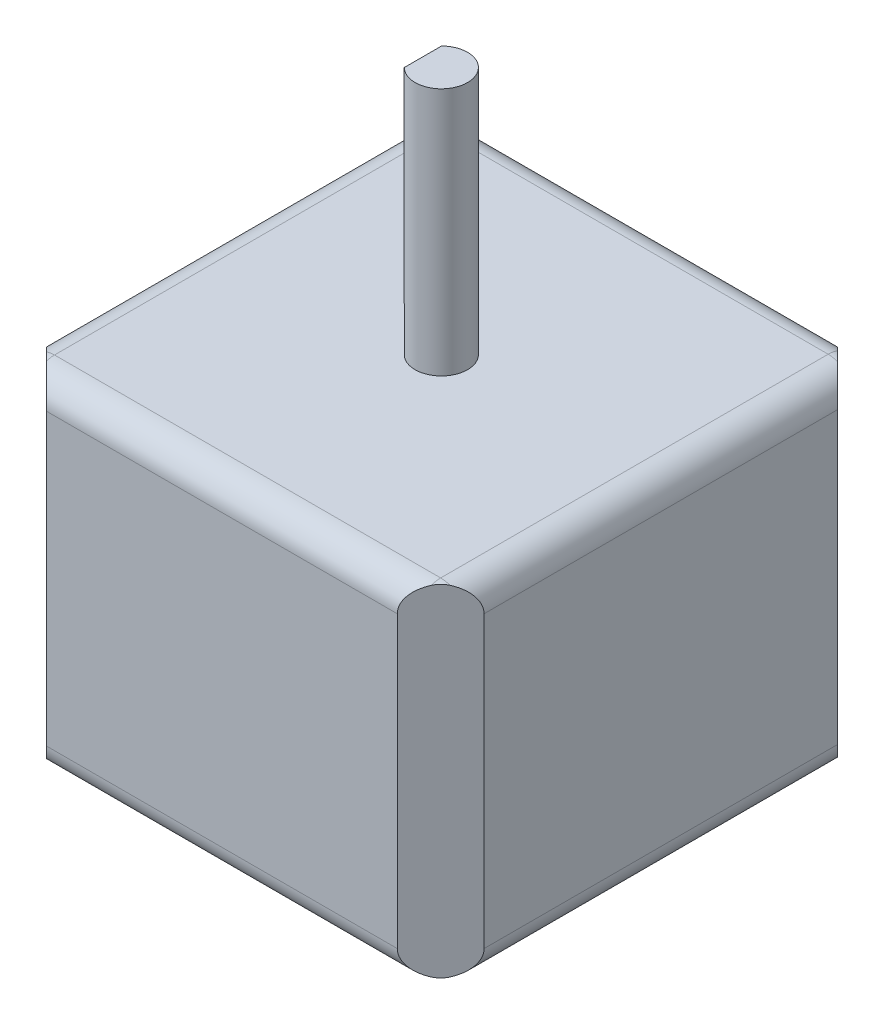
from build123d import *

# Parameters (mm, degrees)
SKETCH1_W           = 42.291
SKETCH1_H           = 33.02
BOSS_EXTRUDE1_DEPTH = 42.418
FILLET1_R           = 2.54
SKETCH2_R           = 2.5273
BOSS_EXTRUDE2_DEPTH = 23.9649
CUT_EXTRUDE2_DEPTH  = 18.288
CUT_EXTRUDE3_REACH  = 58.985


with BuildPart() as part:
    # Sketch1 → Boss-Extrude1 (new body)
    with BuildSketch(Plane.XY):
        Rectangle(SKETCH1_W, SKETCH1_H)
    extrude(amount=BOSS_EXTRUDE1_DEPTH)

    # Fillet1
    fillet1_edges = [part.edges().sort_by_distance(p)[0] for p in [
        (21.1455, 0, 42.418),
        (0, 16.51, 42.418),
        (-21.1455, 0, 42.418),
        (0, 16.51, 0),
        (21.1455, 0, 0),
        (0, -16.51, 0),
        (-21.1455, 0, 0),
        (0, -16.51, 42.418),
        (-21.1455, 16.51, 21.209),
        (21.1455, 16.51, 21.209),
        (21.1455, -16.51, 21.209),
        (-21.1455, -16.51, 21.209),
    ]]
    fillet(fillet1_edges, radius=FILLET1_R)

    # Sketch2 → Boss-Extrude2 (add)
    with BuildSketch(Plane(origin=(0, 16.51, 0), x_dir=(1, 0, 0), z_dir=(0, 1, 0))):
        with Locations((0, -21.209)):
            Circle(SKETCH2_R)
    extrude(amount=BOSS_EXTRUDE2_DEPTH)

    # Sketch4 → Cut-Extrude2 (cut)
    with BuildSketch(Plane(origin=(0, 40.4749, 0), x_dir=(1, 0, 0), z_dir=(0, 1, 0))):
        with BuildLine():
            Line((-1.778, -23.005096125), (-1.778, -19.412903875))
            ThreePointArc((-1.778, -19.412903875), (-2.5273, -21.209), (-1.778, -23.005096125))
        make_face()
    extrude(amount=-CUT_EXTRUDE2_DEPTH, mode=Mode.SUBTRACT)

    # Sketch5 → Cut-Extrude3 (cut, up to next)
    with BuildSketch(Plane.XZ.offset(16.51), mode=Mode.PRIVATE) as cut_extrude3_sk1:
        Polygon((-21.1455, 42.418), (-21.1455, 38.107477062), (-16.834977062, 42.418), align=None)
    cut_extrude3_tool1 = extrude(cut_extrude3_sk1.sketch, amount=-CUT_EXTRUDE3_REACH, mode=Mode.PRIVATE) & part.part
    add(cut_extrude3_tool1.solids().sort_by_distance((-19.708659, -16.51, 40.981159))[0], mode=Mode.SUBTRACT)
    # Sketch5 → Cut-Extrude3 (cut, up to next)
    with BuildSketch(Plane.XZ.offset(16.51), mode=Mode.PRIVATE) as cut_extrude3_sk2:
        Polygon((16.961977062, 42.418), (21.2725, 38.107477062), (21.2725, 42.418), align=None)
    cut_extrude3_tool2 = extrude(cut_extrude3_sk2.sketch, amount=-CUT_EXTRUDE3_REACH, mode=Mode.PRIVATE) & part.part
    add(cut_extrude3_tool2.solids().sort_by_distance((19.835659, -16.51, 40.981159))[0], mode=Mode.SUBTRACT)
    # Sketch5 → Cut-Extrude3 (cut, up to next)
    with BuildSketch(Plane.XZ.offset(16.51), mode=Mode.PRIVATE) as cut_extrude3_sk3:
        Polygon((-21.1455, 0), (-16.834977062, 0), (-21.1455, 4.310522938), align=None)
    cut_extrude3_tool3 = extrude(cut_extrude3_sk3.sketch, amount=-CUT_EXTRUDE3_REACH, mode=Mode.PRIVATE) & part.part
    add(cut_extrude3_tool3.solids().sort_by_distance((-19.708659, -16.51, 1.436841))[0], mode=Mode.SUBTRACT)
    # Sketch5 → Cut-Extrude3 (cut, up to next)
    with BuildSketch(Plane.XZ.offset(16.51), mode=Mode.PRIVATE) as cut_extrude3_sk4:
        Polygon((21.2725, 0), (21.2725, 4.310522938), (16.961977062, 0), align=None)
    cut_extrude3_tool4 = extrude(cut_extrude3_sk4.sketch, amount=-CUT_EXTRUDE3_REACH, mode=Mode.PRIVATE) & part.part
    add(cut_extrude3_tool4.solids().sort_by_distance((19.835659, -16.51, 1.436841))[0], mode=Mode.SUBTRACT)


solid = part.part
